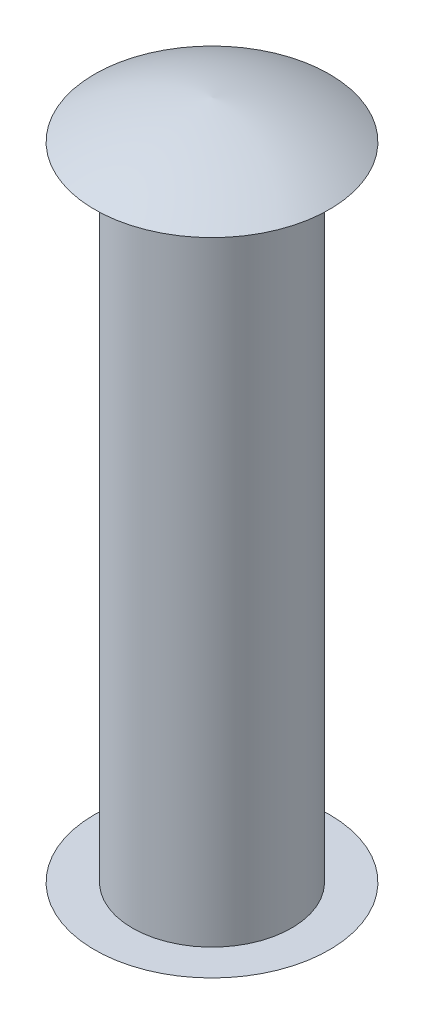
from build123d import *

# Parameters (mm, degrees)
SKETCH1_R           = 3.175
BOSS_EXTRUDE1_DEPTH = 12.7889


with BuildPart() as part:
    # Sketch1 → Boss-Extrude1 (new body, symmetric)
    with BuildSketch(Plane(origin=(0, 0, 0), x_dir=(1, 0, 0), z_dir=(0, 1, 0))):
        Circle(SKETCH1_R)
    extrude(amount=BOSS_EXTRUDE1_DEPTH, both=True)

    # Sketch3 → Revolve1 (revolve)
    with BuildSketch(Plane.XY):
        with BuildLine():
            Line((0, 12.7889), (-4.68122, 12.7889))
            add(Edge.make_bspline(
                [(-4.68122, 12.7889), (-2.485687352, 14.067463283), (0, 14.3129)],
                knots=[0, 0, 0, 1, 1, 1], degree=2))
            Line((0, 14.3129), (0, 12.7889))
        make_face()
    revolve1 = revolve(axis=Axis((0, 12.7889, 0), (0, 1, 0)))

    # Mirror1: Revolve1 across plane
    add(revolve1.mirror(Plane.ZX))


solid = part.part
